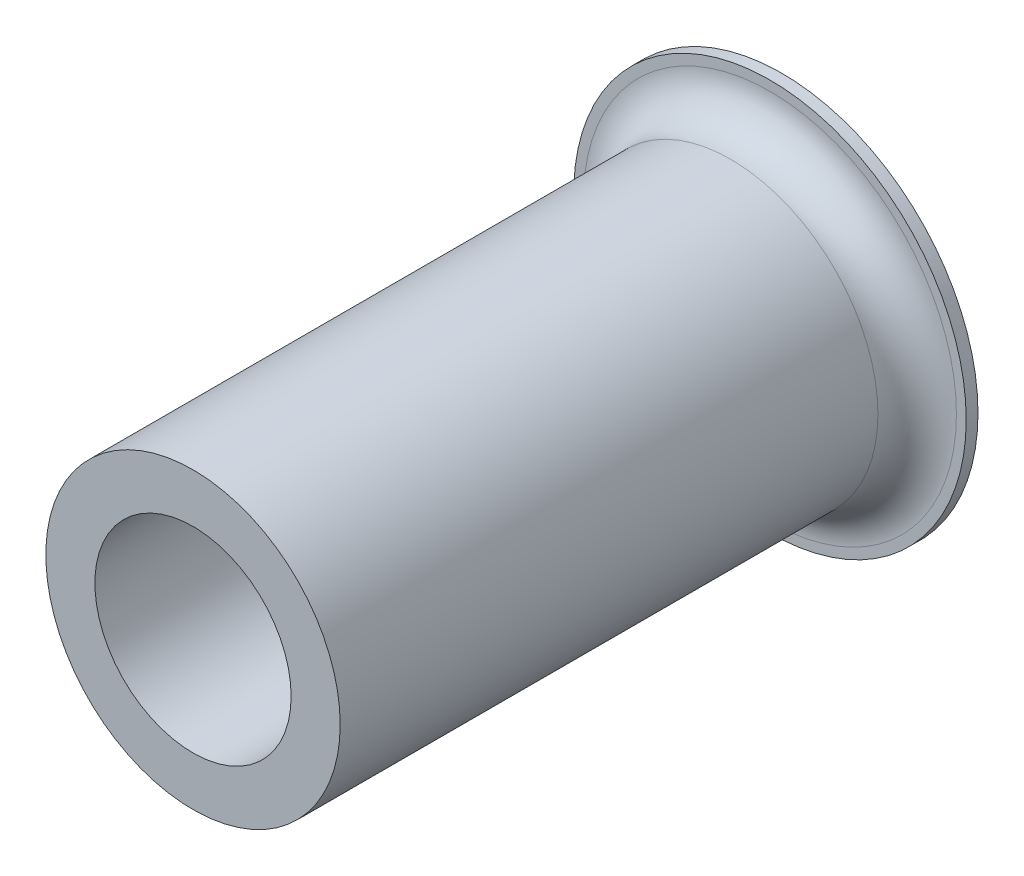
from build123d import *

# Parameters (mm, degrees)
SKETCH1_R           = 37.5
BOSS_EXTRUDE1_DEPTH = 150
CUT_EXTRUDE1_START  = 150
SKETCH2_R           = 25
CUT_EXTRUDE1_DEPTH  = 145
SKETCH3_R           = 50
BOSS_EXTRUDE2_DEPTH = 3
FILLET1_R           = 10


with BuildPart() as part:
    # Sketch1 → Boss-Extrude1 (new body)
    with BuildSketch(Plane.XY):
        Circle(SKETCH1_R)
    extrude(amount=BOSS_EXTRUDE1_DEPTH)

    # Sketch2 → Cut-Extrude1 (cut)
    with BuildSketch(Plane.XY.offset(CUT_EXTRUDE1_START)):
        Circle(SKETCH2_R)
    extrude(amount=-CUT_EXTRUDE1_DEPTH, mode=Mode.SUBTRACT)

    # Sketch3 → Boss-Extrude2 (add)
    with BuildSketch(Plane.XY):
        Circle(SKETCH3_R)
    extrude(amount=BOSS_EXTRUDE2_DEPTH)

    # Fillet1
    fillet1_edges = [part.edges().sort_by_distance(p)[0] for p in [
        (-37.5, 0, 3),
    ]]
    fillet(fillet1_edges, radius=FILLET1_R)


solid = part.part
